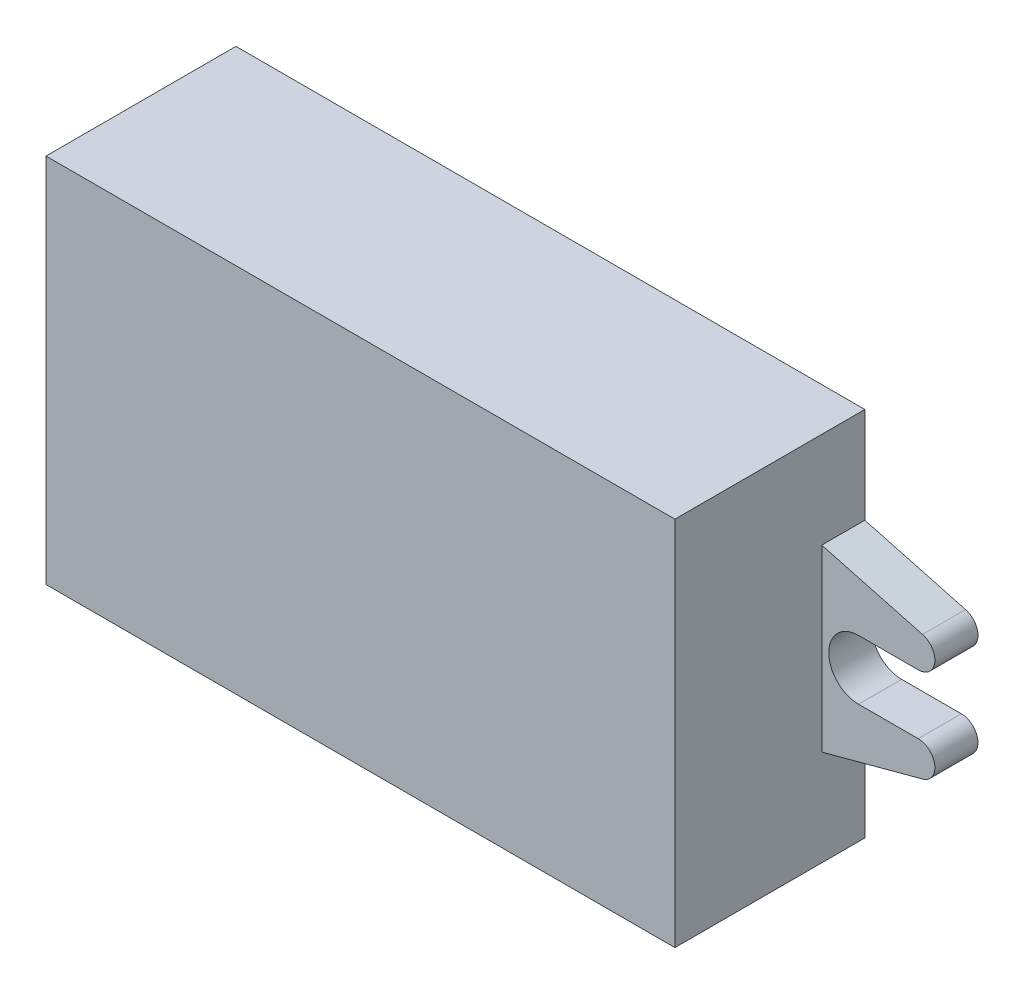
from build123d import *

# Parameters (mm, degrees)
SKETCH1_W           = 46.35
SKETCH1_H           = 27.35
BOSS_EXTRUDE1_DEPTH = 14
BOSS_EXTRUDE2_DEPTH = 3.175


with BuildPart() as part:
    # Sketch1 → Boss-Extrude1 (new body)
    with BuildSketch(Plane.XY):
        Rectangle(SKETCH1_W, SKETCH1_H)
    extrude(amount=BOSS_EXTRUDE1_DEPTH)

    # Sketch2 → Boss-Extrude2 (add)
    with BuildSketch(Plane.XY):
        with BuildLine():
            Line((23.175, 6.604134349), (30.60317409, 4.6137611))
            ThreePointArc((30.60317409, 4.6137611), (31.504475179, 3.264868697), (30.284766137, 2.195212576))
            Line((30.284766137, 2.195212576), (25.885652609, 2.195212576))
            ThreePointArc((25.885652609, 2.195212576), (23.690440034, 0), (25.885652609, -2.195212576))
            Line((25.885652609, -2.195212576), (30.284766137, -2.195212576))
            ThreePointArc((30.284766137, -2.195212576), (31.504475179, -3.264868697), (30.60317409, -4.6137611))
            Line((30.60317409, -4.6137611), (23.175, -6.604134349))
            Line((23.175, -6.604134349), (23.175, 6.604134349))
        make_face()
    boss_extrude2 = extrude(amount=BOSS_EXTRUDE2_DEPTH)

    # Mirror1: Boss-Extrude2 across plane
    add(boss_extrude2.mirror(Plane(origin=(0, 0, 0), x_dir=(0, 0, 1), z_dir=(1, 0, 0))))


solid = part.part
